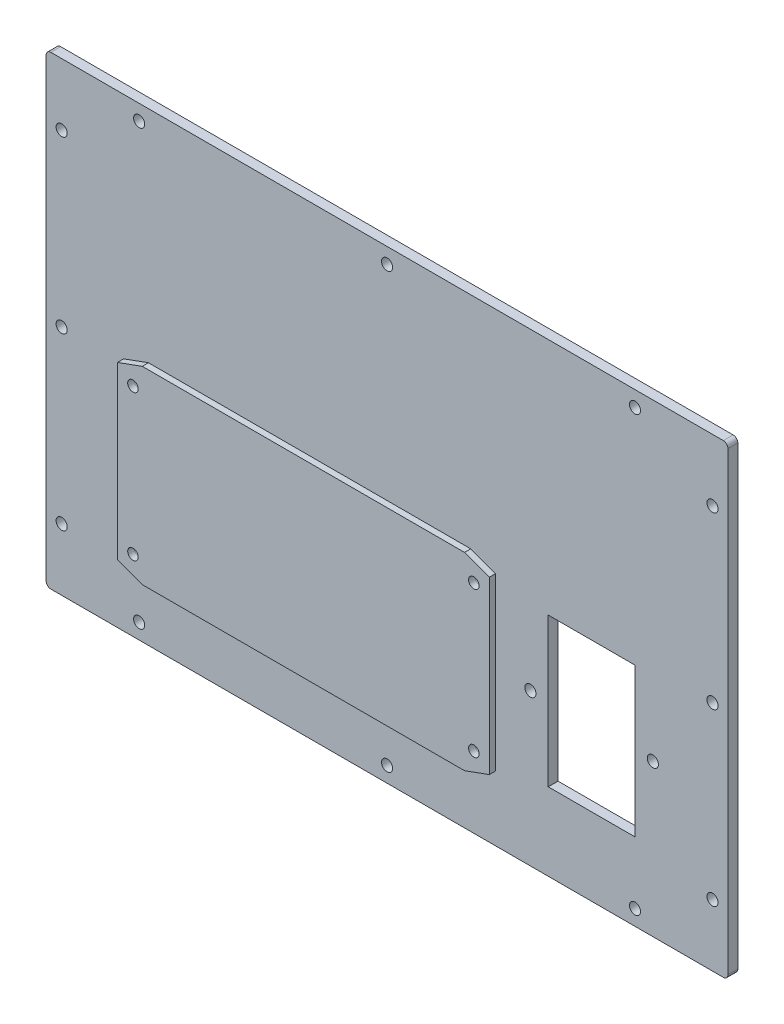
from build123d import *

# Parameters (mm, degrees)
SKETCH1_W            = 220
SKETCH1_H            = 150
BOSS_EXTRUDE1_DEPTH  = 3.175
M3_CLEARANCE_HOLE1_D = 3.6
SKETCH4_W            = 10
SKETCH4_H            = 10
BOSS_EXTRUDE2_DEPTH  = 3.175
FILLET2_R            = 1.5
SKETCH5_W            = 28
SKETCH5_H            = 48
CUT_EXTRUDE1_DEPTH   = 134.173122758
M3_CLEARANCE_HOLE2_D = 3.6
SKETCH8_W            = 100
SKETCH8_H            = 57
CUT_EXTRUDE2_DEPTH   = 134.173122758
M3_CLEARANCE_HOLE3_D = 3.4
SKETCH11_R           = 1.7
SKETCH11_W           = 50
SKETCH11_H           = 57
BOSS_EXTRUDE3_DEPTH  = 2
SKETCH12_W           = 98
SKETCH12_H           = 55
BOSS_EXTRUDE5_DEPTH  = 2


with BuildPart() as part:
    # Sketch1 → Boss-Extrude1 (new body)
    with BuildSketch(Plane.XY):
        Rectangle(SKETCH1_W, SKETCH1_H)
    extrude(amount=BOSS_EXTRUDE1_DEPTH)

    # M3 Clearance Hole1 (through all)
    with Locations(Plane.XY.offset(3.175)):
        with Locations((0, 0), (-80, 70), (80, 70), (0, 70), (-105, 55), (-105, 0), (-105, -55), (-80, -70), (0, -70), (80, -70), (105, -55), (105, 0), (105, 55)):
            Hole(M3_CLEARANCE_HOLE1_D / 2)

    # Sketch4 → Boss-Extrude2 (add, through all)
    with BuildSketch(Plane.XY.offset(3.175)):
        Rectangle(SKETCH4_W, SKETCH4_H)
    extrude(amount=-BOSS_EXTRUDE2_DEPTH)

    # Fillet2
    fillet2_edges = [part.edges().sort_by_distance(p)[0] for p in [
        (-110, -75, 1.5875),
        (-110, 75, 1.5875),
        (110, 75, 1.5875),
        (110, -75, 1.5875),
    ]]
    fillet(fillet2_edges, radius=FILLET2_R)

    # Sketch5 → Cut-Extrude1 (cut, through all)
    with BuildSketch(Plane.XY.offset(3.175)):
        with Locations((66, -26)):
            Rectangle(SKETCH5_W, SKETCH5_H)
    extrude(amount=-CUT_EXTRUDE1_DEPTH, mode=Mode.SUBTRACT)

    # M3 Clearance Hole2 (through all)
    with Locations(Plane.XY.offset(3.175)):
        with Locations((46.25, -26), (85.75, -26)):
            Hole(M3_CLEARANCE_HOLE2_D / 2)

    # Sketch8 → Cut-Extrude2 (cut, through all)
    with BuildSketch(Plane.XY.offset(3.175)):
        with Locations((-25, -26.5)):
            Rectangle(SKETCH8_W, SKETCH8_H)
    extrude(amount=-CUT_EXTRUDE2_DEPTH, mode=Mode.SUBTRACT)

    # M3 Clearance Hole3 (through all)
    with Locations(Plane.XY.offset(3.175)):
        with Locations((-80, -3), (-80, -50), (30, -50), (30, -3)):
            Hole(M3_CLEARANCE_HOLE3_D / 2)


with BuildPart() as body_2:
    # Sketch11 → Boss-Extrude3 (new body)
    with BuildSketch(Plane.XY.offset(3.175)):
        Polygon((-77, 4), (-77, -57), (-85, -54.088238126), (-85, 1.088238126), align=None)
        with Locations((-80, -3)):
            Circle(SKETCH11_R, mode=Mode.SUBTRACT)
        with Locations((-80, -50)):
            Circle(SKETCH11_R, mode=Mode.SUBTRACT)
        Polygon((-77, -57), (-25, -57), (-25, -55), (-75, -55), (-75, 2), (-25, 2), (-25, 4), (-77, 4), align=None)
        with Locations((-50, -26.5)):
            Rectangle(SKETCH11_W, SKETCH11_H)
        with Locations((0, -26.5)):
            Rectangle(SKETCH11_W, SKETCH11_H)
        Polygon((-25, -57), (27, -57), (27, 4), (-25, 4), (-25, 2), (25, 2), (25, -55), (-25, -55), align=None)
        Polygon((27, -57), (27, 4), (35, 1.088238126), (35, -54.088238126), align=None)
        with Locations((30, -3)):
            Circle(SKETCH11_R, mode=Mode.SUBTRACT)
        with Locations((30, -50)):
            Circle(SKETCH11_R, mode=Mode.SUBTRACT)
    extrude(amount=BOSS_EXTRUDE3_DEPTH)


with BuildPart() as body_3:
    # Sketch12 → Boss-Extrude5 (new body)
    with BuildSketch(Plane(origin=(0, 0, 3.175), x_dir=(-1, 0, 0), z_dir=(0, 0, -1))):
        with Locations((25, -26.5)):
            Rectangle(SKETCH12_W, SKETCH12_H)
    extrude(amount=BOSS_EXTRUDE5_DEPTH)


solid = Compound([part.part, body_2.part, body_3.part])
